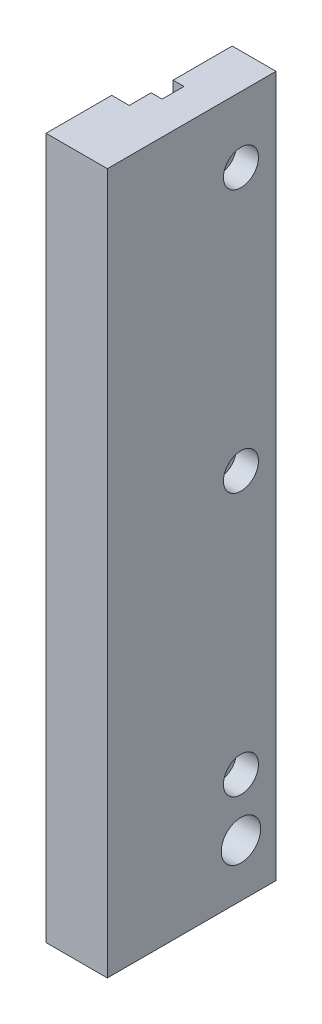
from build123d import *

# Parameters (mm, degrees)
BOSS_EXTRUDE1_DEPTH = 160
SKETCH2_R           = 4
SKETCH2_R_2         = 4.5
CUT_EXTRUDE2_DEPTH  = 5
SKETCH3_R           = 2.5
SKETCH3_R_2         = 4.5
CUT_EXTRUDE3_DEPTH  = 10


with BuildPart() as part:
    # Sketch1 → Boss-Extrude1 (new body)
    with BuildSketch(Plane(origin=(0, 0, 0), x_dir=(1, 0, 0), z_dir=(0, 1, 0))):
        Polygon((0, 20), (2.5, 20), (2.5, 25), (0, 25), (0, 38.5), (10, 38.5), (10, 0), (0, 0), (-4, 0), (-4, 15), (0, 15), align=None)
    extrude(amount=BOSS_EXTRUDE1_DEPTH)

    # Sketch2 → Cut-Extrude2 (cut)
    with BuildSketch(Plane(origin=(10, 0, 0), x_dir=(0, 0, -1), z_dir=(1, 0, 0))):
        with Locations((30.5, 145)):
            Circle(SKETCH2_R)
        with Locations((30.5, 85)):
            Circle(SKETCH2_R)
        with Locations((30.5, 25)):
            Circle(SKETCH2_R)
        with Locations((30.5, 12)):
            Circle(SKETCH2_R_2)
    extrude(amount=-CUT_EXTRUDE2_DEPTH, mode=Mode.SUBTRACT)

    # Sketch3 → Cut-Extrude3 (cut, through all)
    with BuildSketch(Plane(origin=(5, 0, 0), x_dir=(0, 0, -1), z_dir=(1, 0, 0))):
        with Locations((30.5, 145)):
            Circle(SKETCH3_R)
        with Locations((30.5, 85)):
            Circle(SKETCH3_R)
        with Locations((30.5, 25)):
            Circle(SKETCH3_R)
        with Locations((30.5, 12)):
            Circle(SKETCH3_R_2)
    extrude(amount=-CUT_EXTRUDE3_DEPTH, mode=Mode.SUBTRACT)


solid = part.part
